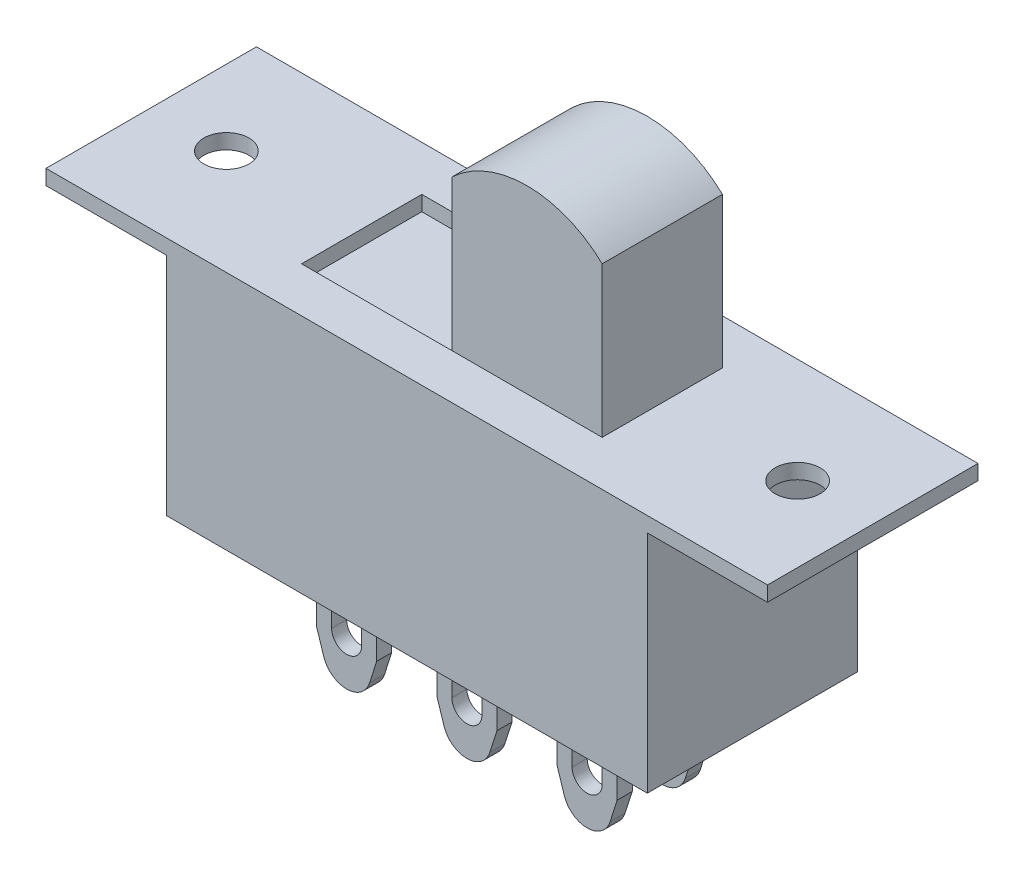
from build123d import *

# Parameters (mm, degrees)
AUFSATZ_LINEAR_AUSTRAGEN1_DEPTH = 3.5
AUFSATZ_LINEAR_AUSTRAGEN2_DEPTH = 2
AUFSATZ_LINEAR_START            = -2
AUFSATZ_LINEAR_AUSTRAGEN3_DEPTH = 0.5
LINEARES_MUSTER1_COUNT          = 3
LINEARES_MUSTER1_PITCH          = 4
LINEARES_MUSTER1_COUNT_DIR2     = 2
LINEARES_MUSTER1_PITCH_DIR2     = 2.5
SKIZZE3_R                       = 0.75
SCHNITT_LINEAR_AUSTRAGEN1_DEPTH = 18.327723451
SKIZZE4_W                       = 5
SKIZZE4_H                       = 4
SCHNITT_LINEAR_AUSTRAGEN2_DEPTH = 0.5


with BuildPart() as part:
    # Skizze1 → Aufsatz-Linear austragen1 (new, symmetric)
    with BuildSketch(Plane.XY):
        Polygon((-12, 8), (-12, 7.5), (-8, 7.5), (-8, 0), (8, 0), (8, 7.5), (12, 7.5), (12, 8), align=None)
    extrude(amount=AUFSATZ_LINEAR_AUSTRAGEN1_DEPTH, both=True)

    # Skizze1_3 → Aufsatz-Linear austragen2 (add, symmetric)
    with BuildSketch(Plane.XY):
        with BuildLine():
            Line((0, 13), (0, 8))
            Line((0, 8), (5, 8))
            Line((5, 8), (5, 13))
            ThreePointArc((5, 13), (2.5, 14), (0, 13))
        make_face()
    extrude(amount=AUFSATZ_LINEAR_AUSTRAGEN2_DEPTH, both=True)


with BuildPart() as body_2:
    # Skizze2 → Aufsatz-Linear austragen3 (new body)
    with BuildSketch(Plane.XY.offset(3.5).offset(AUFSATZ_LINEAR_START)):
        with BuildLine():
            Line((-5, 0), (-5, -2.7))
            Line((-5, -2.7), (-4.76192799, -3.443855979))
            ThreePointArc((-4.76192799, -3.443855979), (-4, -4), (-3.23807201, -3.443855979))
            Line((-3.23807201, -3.443855979), (-3, -2.7))
            Line((-3, -2.7), (-3, 0))
            Line((-3, 0), (-5, 0))
        make_face()
        with BuildLine():
            Line((-3.5, -1.5), (-3.5, -2.5))
            ThreePointArc((-3.5, -2.5), (-4, -3), (-4.5, -2.5))
            Line((-4.5, -2.5), (-4.5, -1.5))
            ThreePointArc((-4.5, -1.5), (-4, -1), (-3.5, -1.5))
        make_face(mode=Mode.SUBTRACT)
    aufsatz_linear_austragen3 = extrude(amount=-AUFSATZ_LINEAR_AUSTRAGEN3_DEPTH)


with BuildPart() as part_1:
    add(part.part)

    # Lineares Muster1: Aufsatz-Linear austragen3 3 × 2
    with Locations(*[(i * LINEARES_MUSTER1_PITCH, 0, -j * LINEARES_MUSTER1_PITCH_DIR2) for i in range(LINEARES_MUSTER1_COUNT) for j in range(LINEARES_MUSTER1_COUNT_DIR2) if (i, j) != (0, 0)]):
        add(aufsatz_linear_austragen3)

    # Skizze3 → Schnitt-Linear austragen1 (cut, through all)
    with BuildSketch(Plane(origin=(0, 8, 0), x_dir=(1, 0, 0), z_dir=(0, 1, 0))):
        with Locations((-9.5, 0)):
            Circle(SKIZZE3_R)
        with Locations((9.5, 0)):
            Circle(SKIZZE3_R)
    extrude(amount=-SCHNITT_LINEAR_AUSTRAGEN1_DEPTH, mode=Mode.SUBTRACT)

    # Skizze4 → Schnitt-Linear austragen2 (cut)
    with BuildSketch(Plane(origin=(0, 8, 0), x_dir=(1, 0, 0), z_dir=(0, 1, 0))):
        with Locations((-2.5, 0)):
            Rectangle(SKIZZE4_W, SKIZZE4_H)
    extrude(amount=-SCHNITT_LINEAR_AUSTRAGEN2_DEPTH, mode=Mode.SUBTRACT)


solid = Compound([body_2.part, part_1.part])
